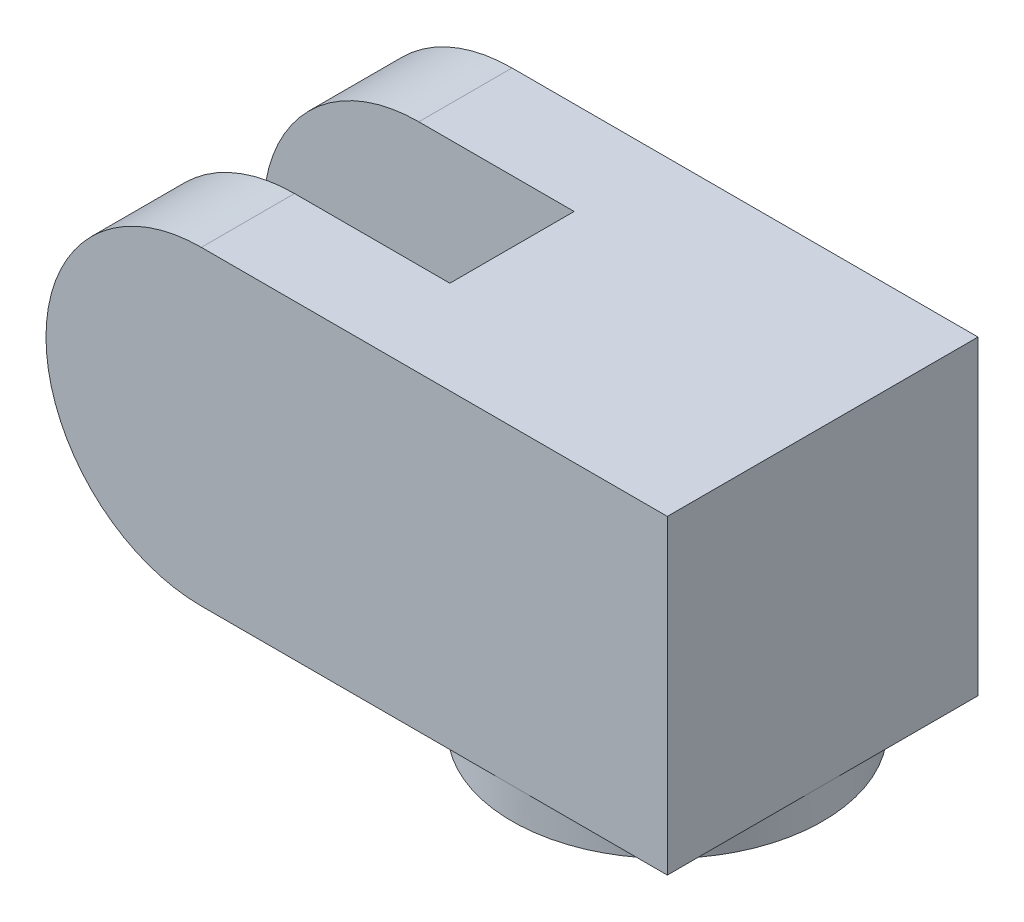
from build123d import *

# Parameters (mm, degrees)
SKETCH_1_W          = 10
SKETCH_1_H          = 10
EXTRUDE_1_DEPTH     = 10
SKETCH_2_W          = 3
SKETCH_2_H          = 10
EXTRUDE_2_DEPTH     = 10
CUT_EXTRUDE_1_DEPTH = 10
SKETCH_4_R          = 5
EXTRUDE_3_DEPTH     = 1


with BuildPart() as part:
    # 草图1 → 凸台-拉伸1 (new body)
    with BuildSketch(Plane(origin=(0, 0, 0), x_dir=(1, 0, 0), z_dir=(0, 1, 0))):
        Rectangle(SKETCH_1_W, SKETCH_1_H)
    extrude(amount=EXTRUDE_1_DEPTH)

    # 草图2 → 凸台-拉伸2 (add)
    with BuildSketch(Plane.ZY.offset(5)):
        with Locations((-3.5, 5)):
            Rectangle(SKETCH_2_W, SKETCH_2_H)
        with Locations((3.5, 5)):
            Rectangle(SKETCH_2_W, SKETCH_2_H)
    extrude(amount=EXTRUDE_2_DEPTH)

    # 草图3 → 切除-拉伸1 (cut)
    with BuildSketch(Plane.XY.offset(5)):
        with BuildLine():
            Line((-10, 10), (-17.018915749, 10))
            Line((-17.018915749, 10), (-17.018915749, 0))
            Line((-17.018915749, 0), (-10, 0))
            ThreePointArc((-10, 0), (-15, 5), (-10, 10))
        make_face()
    extrude(amount=-CUT_EXTRUDE_1_DEPTH, mode=Mode.SUBTRACT)

    # 草图4 → 凸台-拉伸3 (add)
    with BuildSketch(Plane.XZ):
        Circle(SKETCH_4_R)
    extrude(amount=EXTRUDE_3_DEPTH)


solid = part.part
